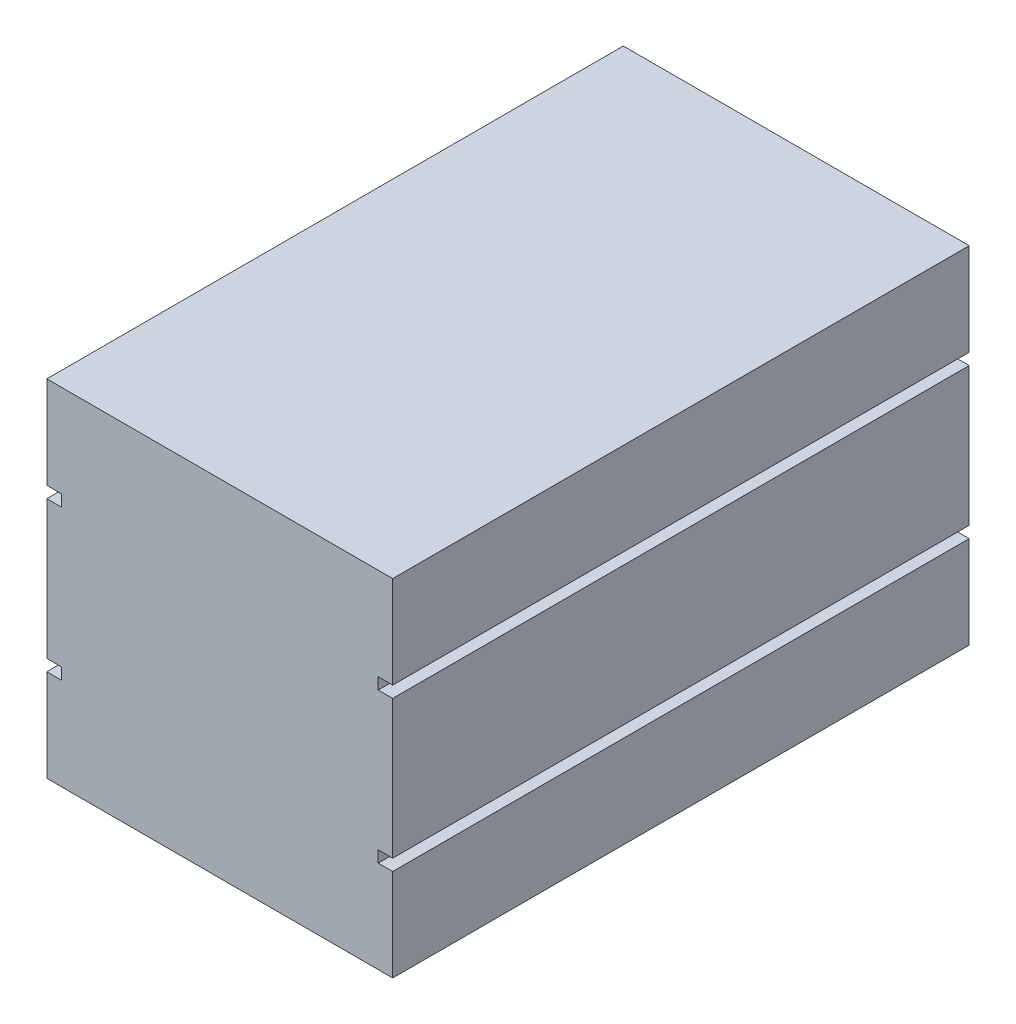
from build123d import *

# Parameters (mm, degrees)
SKETCH1_W           = 50
SKETCH1_H           = 30
BOSS_EXTRUDE1_DEPTH = 30
SKETCH3_R           = 5.933342005
CUT_EXTRUDE1_DEPTH  = 40
SKETCH4_W           = 1.254965376
SKETCH4_H           = 1
CUT_EXTRUDE2_DEPTH  = 51


with BuildPart() as part:
    # Sketch1 → Boss-Extrude1 (new body)
    with BuildSketch(Plane(origin=(0, 0, 0), x_dir=(0, 0, -1), z_dir=(1, 0, 0))):
        Rectangle(SKETCH1_W, SKETCH1_H)
    extrude(amount=BOSS_EXTRUDE1_DEPTH)

    # Sketch3 → Cut-Extrude1 (cut)
    with BuildSketch(Plane(origin=(0, 0, -25), x_dir=(-1, 0, 0), z_dir=(0, 0, -1))):
        with Locations((-15, 0)):
            Circle(SKETCH3_R)
    extrude(amount=-CUT_EXTRUDE1_DEPTH, mode=Mode.SUBTRACT)

    # Sketch4 → Cut-Extrude2 (cut, through all)
    with BuildSketch(Plane(origin=(0, 0, -25), x_dir=(-1, 0, 0), z_dir=(0, 0, -1))):
        with Locations((-29.372517312, 6.5)):
            Rectangle(SKETCH4_W, SKETCH4_H)
        with Locations((-29.372517312, -6.5)):
            Rectangle(SKETCH4_W, SKETCH4_H)
        with Locations((-0.627482688, -6.5)):
            Rectangle(SKETCH4_W, SKETCH4_H)
        with Locations((-0.627482688, 6.5)):
            Rectangle(SKETCH4_W, SKETCH4_H)
    extrude(amount=-CUT_EXTRUDE2_DEPTH, mode=Mode.SUBTRACT)


solid = part.part
